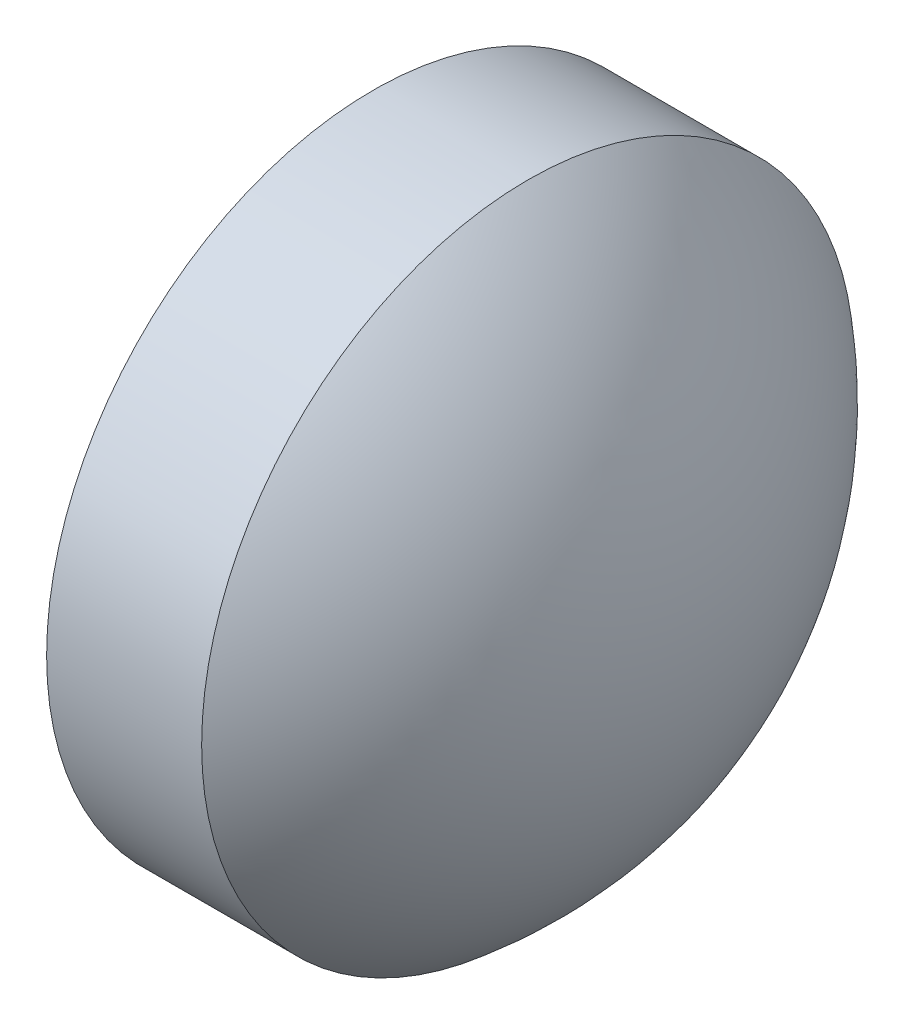
from build123d import *


with BuildPart() as part:
    # 草图1 → 旋转3 (revolve)
    with BuildSketch(Plane.XY, mode=Mode.PRIVATE) as revolve_3_sk:
        with BuildLine():
            Line((424.058339702, 105.48061611), (425.958339719, 105.48061611))
            ThreePointArc((425.958339719, 105.48061611), (425.708770222, 106.587695605), (425.008339702, 107.48061611))
            Line((425.008339702, 107.48061611), (424.058339702, 107.48061611))
            Line((424.058339702, 107.48061611), (424.058339702, 105.48061611))
        make_face()
    revolve(revolve_3_sk.sketch.rotate(Axis((423.428367263, 105.48061611, 0), (1, 0, 0)), 90), axis=Axis((423.428367263, 105.48061611, 0), (1, 0, 0)))  # turned: the seam where the file's is


solid = part.part
